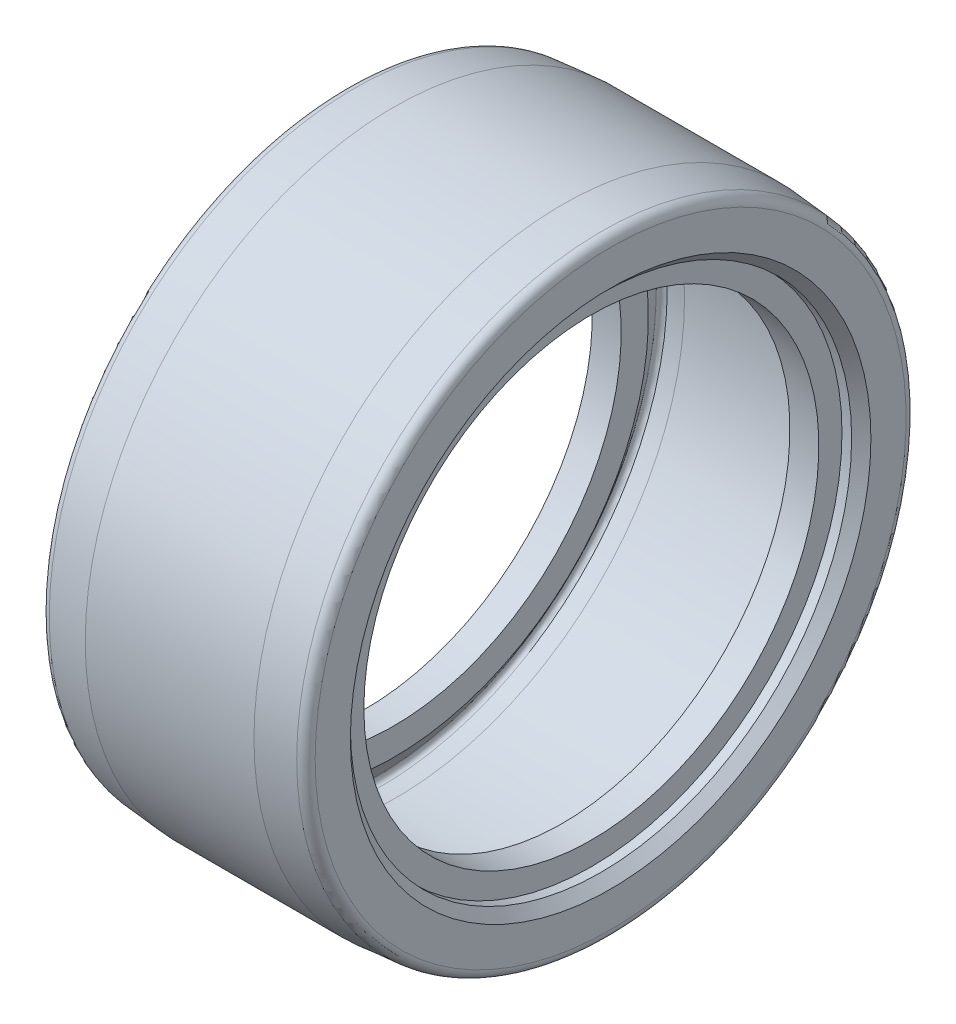
from build123d import *


with BuildPart() as part:
    # Esquisse1 → Révolution1 (revolve)
    with BuildSketch(Plane.XY):
        with BuildLine():
            Line((0, 30.65), (0, 27))
            Line((0, 27), (1, 26))
            Line((1, 26), (2, 26))
            Line((2, 26), (2, 23.6))
            Line((2, 23.6), (5, 23.6))
            Line((5, 23.6), (5, 26.422161222))
            Line((5, 26.422161222), (3.149522108, 29.072161222))
            ThreePointArc((3.149522108, 29.072161222), (3.106544314, 29.570228141), (3.516339637, 29.856559314))
            Line((3.516339637, 29.856559314), (5.173152545, 30))
            Line((5.173152545, 30), (22.325638556, 30))
            Line((22.325638556, 30), (23.987869468, 29.85529344))
            ThreePointArc((23.987869468, 29.85529344), (24.395805636, 29.568829063), (24.353440423, 29.072161222))
            Line((24.353440423, 29.072161222), (22.5, 26.422161222))
            Line((22.5, 26.422161222), (22.5, 23.6))
            Line((22.5, 23.6), (25.5, 23.6))
            Line((25.5, 23.6), (25.5, 26))
            Line((25.5, 26), (26.5, 26))
            Line((26.5, 26), (27.5, 27))
            Line((27.5, 27), (27.5, 30.65))
            ThreePointArc((27.5, 30.65), (27.238547604, 31.328009544), (26.587105785, 31.65))
            Line((26.587105785, 31.65), (22.499950042, 32))
            Line((22.499950042, 32), (5, 32))
            Line((5, 32), (0.91370073, 31.64622344))
            ThreePointArc((0.91370073, 31.64622344), (0.263015483, 31.325890185), (0, 30.65))
        make_face()
    revolve(axis=Axis((0, 0, 0), (1, 0, 0)))


solid = part.part
